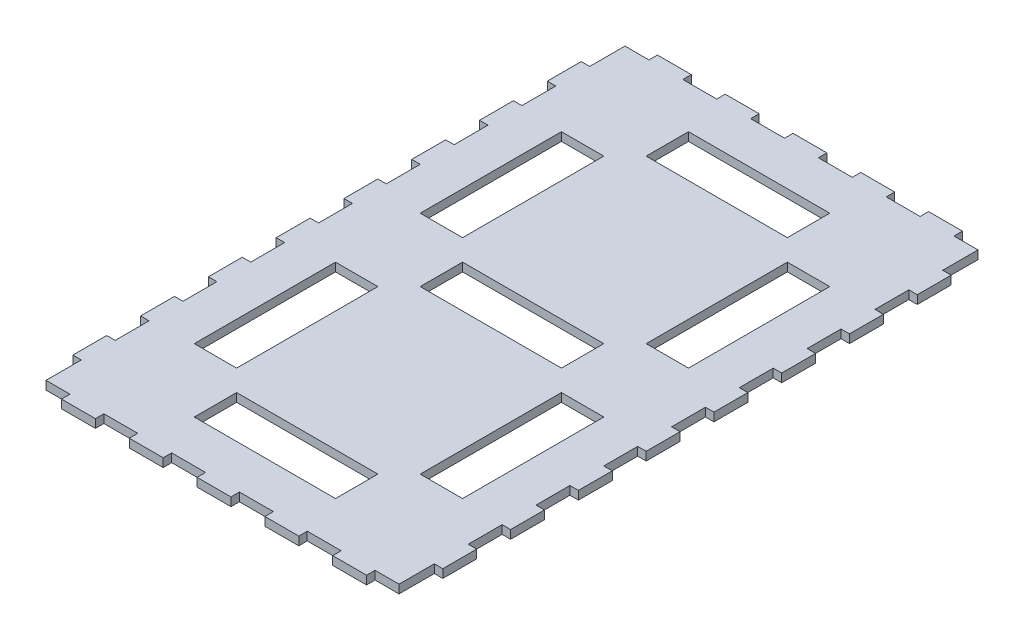
from build123d import *

# Parameters (mm, degrees)
SKETCH3_W           = 125
SKETCH3_H           = 205
BOSS_EXTRUDE1_DEPTH = 3
SKETCH4_W           = 15
SKETCH4_H           = 50
SKETCH4_W_2         = 50
SKETCH4_H_2         = 15
CUT_EXTRUDE1_DEPTH  = 6
SKETCH5_W           = 12
SKETCH5_H           = 3
SKETCH5_W_2         = 3
SKETCH5_H_2         = 12
BOSS_EXTRUDE2_DEPTH = 3


with BuildPart() as part:
    # Sketch3 → Boss-Extrude1 (new body)
    with BuildSketch(Plane(origin=(0, 0, 0), x_dir=(1, 0, 0), z_dir=(0, 1, 0))):
        Rectangle(SKETCH3_W, SKETCH3_H)
    extrude(amount=BOSS_EXTRUDE1_DEPTH)

    # Sketch4 → Cut-Extrude1 (cut)
    with BuildSketch(Plane(origin=(0, 3, 0), x_dir=(1, 0, 0), z_dir=(0, 1, 0))):
        with Locations((-40, 40)):
            Rectangle(SKETCH4_W, SKETCH4_H)
        with Locations((40, 40)):
            Rectangle(SKETCH4_W, SKETCH4_H)
        Rectangle(SKETCH4_W_2, SKETCH4_H_2)
        with Locations((-40, -40)):
            Rectangle(SKETCH4_W, SKETCH4_H)
        with Locations((40, -40)):
            Rectangle(SKETCH4_W, SKETCH4_H)
        with Locations((0, 80)):
            Rectangle(SKETCH4_W_2, SKETCH4_H_2)
        with Locations((0, -80)):
            Rectangle(SKETCH4_W_2, SKETCH4_H_2)
    extrude(amount=-CUT_EXTRUDE1_DEPTH, mode=Mode.SUBTRACT)

    # Sketch5 → Boss-Extrude2 (add)
    with BuildSketch(Plane(origin=(0, 3, 0), x_dir=(1, 0, 0), z_dir=(0, 1, 0))):
        with Locations((24, -104)):
            Rectangle(SKETCH5_W, SKETCH5_H)
        with Locations((0, -104)):
            Rectangle(SKETCH5_W, SKETCH5_H)
        with Locations((-64, -84)):
            Rectangle(SKETCH5_W_2, SKETCH5_H_2)
        with Locations((-64, -60)):
            Rectangle(SKETCH5_W_2, SKETCH5_H_2)
        with Locations((-64, -12)):
            Rectangle(SKETCH5_W_2, SKETCH5_H_2)
        with Locations((64, -84)):
            Rectangle(SKETCH5_W_2, SKETCH5_H_2)
        with Locations((64, -36)):
            Rectangle(SKETCH5_W_2, SKETCH5_H_2)
        with Locations((64, -12)):
            Rectangle(SKETCH5_W_2, SKETCH5_H_2)
        with Locations((64, 12)):
            Rectangle(SKETCH5_W_2, SKETCH5_H_2)
        with Locations((64, 36)):
            Rectangle(SKETCH5_W_2, SKETCH5_H_2)
        with Locations((64, 84)):
            Rectangle(SKETCH5_W_2, SKETCH5_H_2)
        with Locations((24, 104)):
            Rectangle(SKETCH5_W, SKETCH5_H)
        with Locations((0, 104)):
            Rectangle(SKETCH5_W, SKETCH5_H)
        with Locations((-24, 104)):
            Rectangle(SKETCH5_W, SKETCH5_H)
        with Locations((-48, 104)):
            Rectangle(SKETCH5_W, SKETCH5_H)
        with Locations((-64, 36)):
            Rectangle(SKETCH5_W_2, SKETCH5_H_2)
        with Locations((-64, 12)):
            Rectangle(SKETCH5_W_2, SKETCH5_H_2)
        with Locations((48, -104)):
            Rectangle(SKETCH5_W, SKETCH5_H)
        with Locations((-24, -104)):
            Rectangle(SKETCH5_W, SKETCH5_H)
        with Locations((-48, -104)):
            Rectangle(SKETCH5_W, SKETCH5_H)
        with Locations((-64, -36)):
            Rectangle(SKETCH5_W_2, SKETCH5_H_2)
        with Locations((64, -60)):
            Rectangle(SKETCH5_W_2, SKETCH5_H_2)
        with Locations((64, 60)):
            Rectangle(SKETCH5_W_2, SKETCH5_H_2)
        with Locations((48, 104)):
            Rectangle(SKETCH5_W, SKETCH5_H)
        with Locations((-64, 84)):
            Rectangle(SKETCH5_W_2, SKETCH5_H_2)
        with Locations((-64, 60)):
            Rectangle(SKETCH5_W_2, SKETCH5_H_2)
    extrude(amount=-BOSS_EXTRUDE2_DEPTH)


solid = part.part
